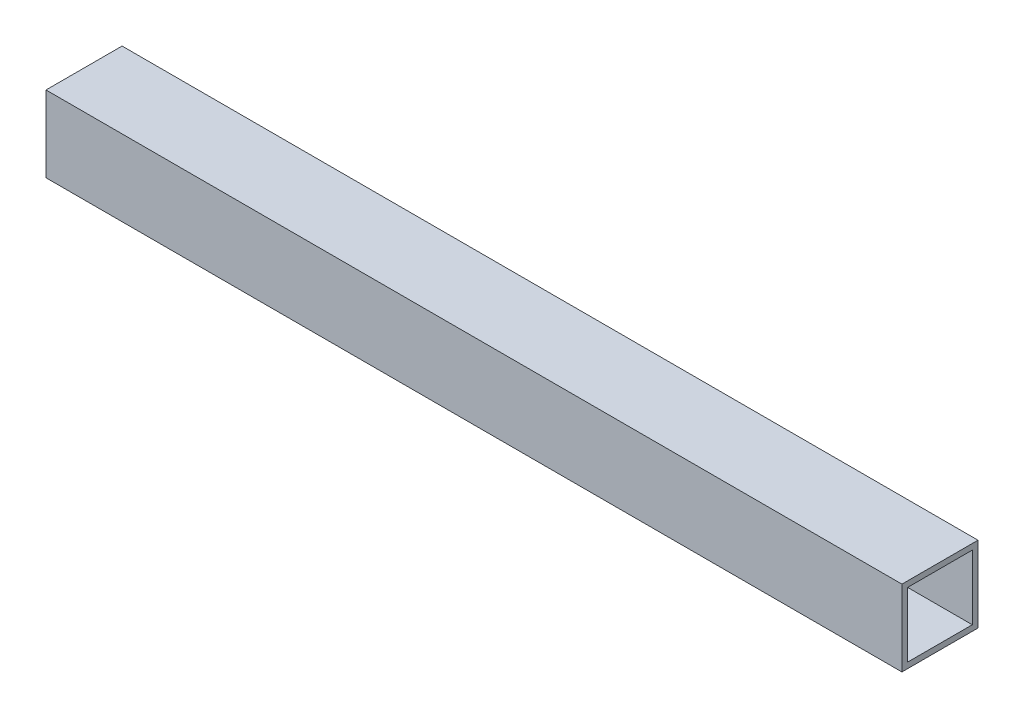
from build123d import *

# Parameters (mm, degrees)
SKETCH1_W           = 450
SKETCH1_H           = 40
BOSS_EXTRUDE1_DEPTH = 40
SKETCH2_W           = 34
SKETCH2_H           = 34
CUT_EXTRUDE1_DEPTH  = 451


with BuildPart() as part:
    # Sketch1 → Boss-Extrude1 (new body)
    with BuildSketch(Plane.XY):
        Rectangle(SKETCH1_W, SKETCH1_H)
    extrude(amount=BOSS_EXTRUDE1_DEPTH)

    # Sketch2 → Cut-Extrude1 (cut, through all)
    with BuildSketch(Plane(origin=(225, 0, 0), x_dir=(0, 0, -1), z_dir=(1, 0, 0))):
        with Locations((-20, 0)):
            Rectangle(SKETCH2_W, SKETCH2_H)
    extrude(amount=-CUT_EXTRUDE1_DEPTH, mode=Mode.SUBTRACT)


solid = part.part
